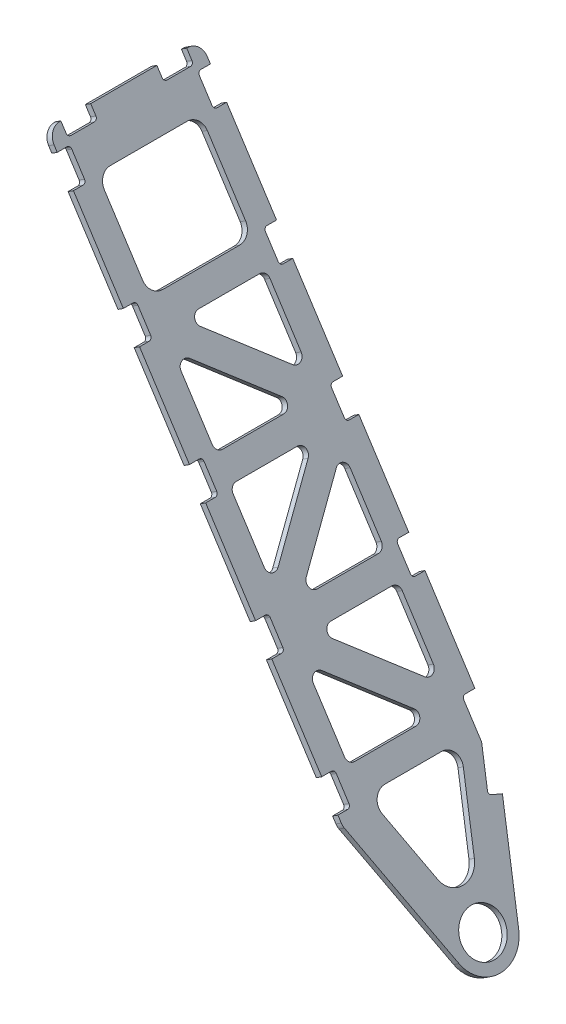
from build123d import *

# Parameters (mm, degrees)
SKETCH1_R           = 42.291
BOSS_EXTRUDE1_DEPTH = 12.7


with BuildPart() as part:
    # Sketch1 → Boss-Extrude1 (new body)
    with BuildSketch(Plane(origin=(106.603890681, 69.014006689, 0), x_dir=(-0.543445635, 0.839444365, 0), z_dir=(0.839444365, 0.543445635, 0))):
        with BuildLine():
            Line((2433.75688, -117.142768), (2433.75688, -136.200768))
            Line((2433.75688, -136.200768), (2445.44088, -136.200768))
            ThreePointArc((2445.44088, -136.200768), (2463.047838852, -128.907726852), (2470.34088, -111.300768))
            Line((2470.34088, -111.300768), (2470.34088, -109.141768))
            Line((2470.34088, -109.141768), (2451.28288, -109.141768))
            ThreePointArc((2451.28288, -109.141768), (2446.792751939, -107.281896061), (2444.93288, -102.791768))
            Line((2444.93288, -102.791768), (2444.93288, -56.309772))
            ThreePointArc((2444.93288, -56.309772), (2446.792751939, -51.819643939), (2451.28288, -49.959772))
            Line((2451.28288, -49.959772), (2470.34088, -49.959772))
            Line((2470.34088, -49.959772), (2470.34088, 81.358228))
            Line((2470.34088, 81.358228), (2451.28288, 81.358228))
            ThreePointArc((2451.28288, 81.358228), (2446.792751939, 83.218099939), (2444.93288, 87.708228))
            Line((2444.93288, 87.708228), (2444.93288, 134.190232))
            ThreePointArc((2444.93288, 134.190232), (2446.792751939, 138.680360061), (2451.28288, 140.540232))
            Line((2451.28288, 140.540232), (2470.34088, 140.540232))
            Line((2470.34088, 140.540232), (2470.34088, 142.699232))
            ThreePointArc((2470.34088, 142.699232), (2463.047838852, 160.306190852), (2445.44088, 167.599232))
            Line((2445.44088, 167.599232), (2433.75688, 167.599232))
            Line((2433.75688, 167.599232), (2433.75688, 148.541232))
            ThreePointArc((2433.75688, 148.541232), (2431.897008061, 144.051103939), (2427.40688, 142.191232))
            Line((2427.40688, 142.191232), (2380.92488, 142.191232))
            ThreePointArc((2380.92488, 142.191232), (2376.434751939, 144.051103939), (2374.57488, 148.541232))
            Line((2374.57488, 148.541232), (2374.57488, 167.599232))
            Line((2374.57488, 167.599232), (2192.45688, 167.599232))
            Line((2192.45688, 167.599232), (2192.45688, 148.541232))
            ThreePointArc((2192.45688, 148.541232), (2190.597008061, 144.051103939), (2186.10688, 142.191232))
            Line((2186.10688, 142.191232), (2139.62488, 142.191232))
            ThreePointArc((2139.62488, 142.191232), (2135.134751939, 144.051103939), (2133.27488, 148.541232))
            Line((2133.27488, 148.541232), (2133.27488, 167.599232))
            Line((2133.27488, 167.599232), (1951.15688, 167.599232))
            Line((1951.15688, 167.599232), (1951.15688, 148.541232))
            ThreePointArc((1951.15688, 148.541232), (1949.297008061, 144.051103939), (1944.80688, 142.191232))
            Line((1944.80688, 142.191232), (1898.32488, 142.191232))
            ThreePointArc((1898.32488, 142.191232), (1893.834751939, 144.051103939), (1891.97488, 148.541232))
            Line((1891.97488, 148.541232), (1891.97488, 167.599232))
            Line((1891.97488, 167.599232), (1709.85688, 167.599232))
            Line((1709.85688, 167.599232), (1709.85688, 148.541232))
            ThreePointArc((1709.85688, 148.541232), (1707.997008061, 144.051103939), (1703.50688, 142.191232))
            Line((1703.50688, 142.191232), (1657.02488, 142.191232))
            ThreePointArc((1657.02488, 142.191232), (1652.534751939, 144.051103939), (1650.67488, 148.541232))
            Line((1650.67488, 148.541232), (1650.67488, 167.599232))
            Line((1650.67488, 167.599232), (1468.55688, 167.599232))
            Line((1468.55688, 167.599232), (1468.55688, 148.541232))
            ThreePointArc((1468.55688, 148.541232), (1466.697008061, 144.051103939), (1462.20688, 142.191232))
            Line((1462.20688, 142.191232), (1415.72488, 142.191232))
            ThreePointArc((1415.72488, 142.191232), (1411.234751939, 144.051103939), (1409.37488, 148.541232))
            Line((1409.37488, 148.541232), (1409.37488, 167.599232))
            Line((1409.37488, 167.599232), (1397.098564625, 167.599232))
            ThreePointArc((1397.098564625, 167.599232), (1392.774725001, 167.22094505), (1388.582263056, 166.097578258))
            Line((1388.582263056, 166.097578258), (1138.01861097, 74.89986711))
            ThreePointArc((1138.01861097, 74.89986711), (1096.56588, 15.699232), (1138.01861097, -43.50140311))
            Line((1138.01861097, -43.50140311), (1317.923948046, -108.981590791))
            Line((1317.923948046, -108.981590791), (1324.442167938, -91.072928824))
            ThreePointArc((1324.442167938, -91.072928824), (1327.725590118, -87.489702286), (1332.58104399, -87.277708592))
            Line((1332.58104399, -87.277708592), (1396.135987148, -110.409816142))
            ThreePointArc((1396.135987148, -110.409816142), (1397.20514913, -110.696297232), (1398.307815058, -110.792768))
            Line((1398.307815058, -110.792768), (1462.20688, -110.792768))
            ThreePointArc((1462.20688, -110.792768), (1466.697008061, -112.652639939), (1468.55688, -117.142768))
            Line((1468.55688, -117.142768), (1468.55688, -136.200768))
            Line((1468.55688, -136.200768), (1650.67488, -136.200768))
            Line((1650.67488, -136.200768), (1650.67488, -117.142768))
            ThreePointArc((1650.67488, -117.142768), (1652.534751939, -112.652639939), (1657.02488, -110.792768))
            Line((1657.02488, -110.792768), (1703.50688, -110.792768))
            ThreePointArc((1703.50688, -110.792768), (1707.997008061, -112.652639939), (1709.85688, -117.142768))
            Line((1709.85688, -117.142768), (1709.85688, -136.200768))
            Line((1709.85688, -136.200768), (1891.97488, -136.200768))
            Line((1891.97488, -136.200768), (1891.97488, -117.142768))
            ThreePointArc((1891.97488, -117.142768), (1893.834751939, -112.652639939), (1898.32488, -110.792768))
            Line((1898.32488, -110.792768), (1944.80688, -110.792768))
            ThreePointArc((1944.80688, -110.792768), (1949.297008061, -112.652639939), (1951.15688, -117.142768))
            Line((1951.15688, -117.142768), (1951.15688, -136.200768))
            Line((1951.15688, -136.200768), (2133.27488, -136.200768))
            Line((2133.27488, -136.200768), (2133.27488, -117.142768))
            ThreePointArc((2133.27488, -117.142768), (2135.134751939, -112.652639939), (2139.62488, -110.792768))
            Line((2139.62488, -110.792768), (2186.10688, -110.792768))
            ThreePointArc((2186.10688, -110.792768), (2190.597008061, -112.652639939), (2192.45688, -117.142768))
            Line((2192.45688, -117.142768), (2192.45688, -136.200768))
            Line((2192.45688, -136.200768), (2374.57488, -136.200768))
            Line((2374.57488, -136.200768), (2374.57488, -117.142768))
            ThreePointArc((2374.57488, -117.142768), (2376.434751939, -112.652639939), (2380.92488, -110.792768))
            Line((2380.92488, -110.792768), (2427.40688, -110.792768))
            ThreePointArc((2427.40688, -110.792768), (2431.897008061, -112.652639939), (2433.75688, -117.142768))
        make_face()
        with Locations(Location((1159.56588, 15.699232, 0), (0, 0, 180))):  # turned: the seam where the file's is
            Circle(SKETCH1_R, mode=Mode.SUBTRACT)
        with BuildLine():
            Line((2001.46712858, -64.172745099), (2115.135988905, 57.074039248))
            ThreePointArc((2115.135988905, 57.074039248), (2129.620024495, 60.32108381), (2137.96588, 48.046016347))
            Line((2137.96588, 48.046016347), (2137.96588, -73.200768))
            ThreePointArc((2137.96588, -73.200768), (2134.099689512, -82.534577512), (2124.76588, -86.400768))
            Line((2124.76588, -86.400768), (2011.097019675, -86.400768))
            ThreePointArc((2011.097019675, -86.400768), (1998.984837743, -78.448152954), (2001.46712858, -64.172745099))
        make_face(mode=Mode.SUBTRACT)
        with BuildLine():
            Line((1873.835988905, -25.675575248), (1760.16712858, 95.571209099))
            ThreePointArc((1760.16712858, 95.571209099), (1757.684837743, 109.846616954), (1769.797019675, 117.799232))
            Line((1769.797019675, 117.799232), (1883.46588, 117.799232))
            ThreePointArc((1883.46588, 117.799232), (1892.799689512, 113.933041512), (1896.66588, 104.599232))
            Line((1896.66588, 104.599232), (1896.66588, -16.647552347))
            ThreePointArc((1896.66588, -16.647552347), (1888.320024495, -28.92261981), (1873.835988905, -25.675575248))
        make_face(mode=Mode.SUBTRACT)
        with BuildLine():
            Line((1959.66588, 117.799232), (2073.334740325, 117.799232))
            ThreePointArc((2073.334740325, 117.799232), (2085.446922257, 109.846616954), (2082.96463142, 95.571209099))
            Line((2082.96463142, 95.571209099), (1969.295771095, -25.675575248))
            ThreePointArc((1969.295771095, -25.675575248), (1954.811735505, -28.92261981), (1946.46588, -16.647552347))
            Line((1946.46588, -16.647552347), (1946.46588, 104.599232))
            ThreePointArc((1946.46588, 104.599232), (1950.332070488, 113.933041512), (1959.66588, 117.799232))
        make_face(mode=Mode.SUBTRACT)
        with BuildLine():
            Line((1518.86712858, -64.172745099), (1632.535988905, 57.074039248))
            ThreePointArc((1632.535988905, 57.074039248), (1647.020024495, 60.32108381), (1655.36588, 48.046016347))
            Line((1655.36588, 48.046016347), (1655.36588, -73.200768))
            ThreePointArc((1655.36588, -73.200768), (1651.499689512, -82.534577512), (1642.16588, -86.400768))
            Line((1642.16588, -86.400768), (1528.497019675, -86.400768))
            ThreePointArc((1528.497019675, -86.400768), (1516.384837743, -78.448152954), (1518.86712858, -64.172745099))
        make_face(mode=Mode.SUBTRACT)
        with BuildLine():
            Line((1832.034740325, -86.400768), (1718.36588, -86.400768))
            ThreePointArc((1718.36588, -86.400768), (1709.032070488, -82.534577512), (1705.16588, -73.200768))
            Line((1705.16588, -73.200768), (1705.16588, 48.046016347))
            ThreePointArc((1705.16588, 48.046016347), (1713.511735505, 60.32108381), (1727.995771095, 57.074039248))
            Line((1727.995771095, 57.074039248), (1841.66463142, -64.172745099))
            ThreePointArc((1841.66463142, -64.172745099), (1844.146922257, -78.448152954), (1832.034740325, -86.400768))
        make_face(mode=Mode.SUBTRACT)
        with BuildLine():
            Line((1477.06588, 117.799232), (1590.734740325, 117.799232))
            ThreePointArc((1590.734740325, 117.799232), (1602.846922257, 109.846616954), (1600.36463142, 95.571209099))
            Line((1600.36463142, 95.571209099), (1486.695771095, -25.675575248))
            ThreePointArc((1486.695771095, -25.675575248), (1472.211735505, -28.92261981), (1463.86588, -16.647552347))
            Line((1463.86588, -16.647552347), (1463.86588, 104.599232))
            ThreePointArc((1463.86588, 104.599232), (1467.732070488, 113.933041512), (1477.06588, 117.799232))
        make_face(mode=Mode.SUBTRACT)
        with BuildLine():
            Line((2379.26588, 91.899232), (2379.26588, -60.500768))
            ThreePointArc((2379.26588, -60.500768), (2371.679945633, -78.814833633), (2353.36588, -86.400768))
            Line((2353.36588, -86.400768), (2213.66588, -86.400768))
            ThreePointArc((2213.66588, -86.400768), (2195.351814367, -78.814833633), (2187.76588, -60.500768))
            Line((2187.76588, -60.500768), (2187.76588, 91.899232))
            ThreePointArc((2187.76588, 91.899232), (2195.351814367, 110.213297633), (2213.66588, 117.799232))
            Line((2213.66588, 117.799232), (2353.36588, 117.799232))
            ThreePointArc((2353.36588, 117.799232), (2371.679945633, 110.213297633), (2379.26588, 91.899232))
        make_face(mode=Mode.SUBTRACT)
        with BuildLine():
            Line((1414.06588, 71.872712132), (1414.06588, -40.474248132))
            ThreePointArc((1414.06588, -40.474248132), (1403.021509702, -61.690286079), (1379.307558288, -64.812287011))
            Line((1379.307558288, -64.812287011), (1257.760850114, -20.572903162))
            ThreePointArc((1257.760850114, -20.572903162), (1232.362827646, 15.699232), (1257.760850114, 51.971367162))
            Line((1257.760850114, 51.971367162), (1379.307558288, 96.210751011))
            ThreePointArc((1379.307558288, 96.210751011), (1403.021509702, 93.088750079), (1414.06588, 71.872712132))
        make_face(mode=Mode.SUBTRACT)
    extrude(amount=-BOSS_EXTRUDE1_DEPTH)


solid = part.part
